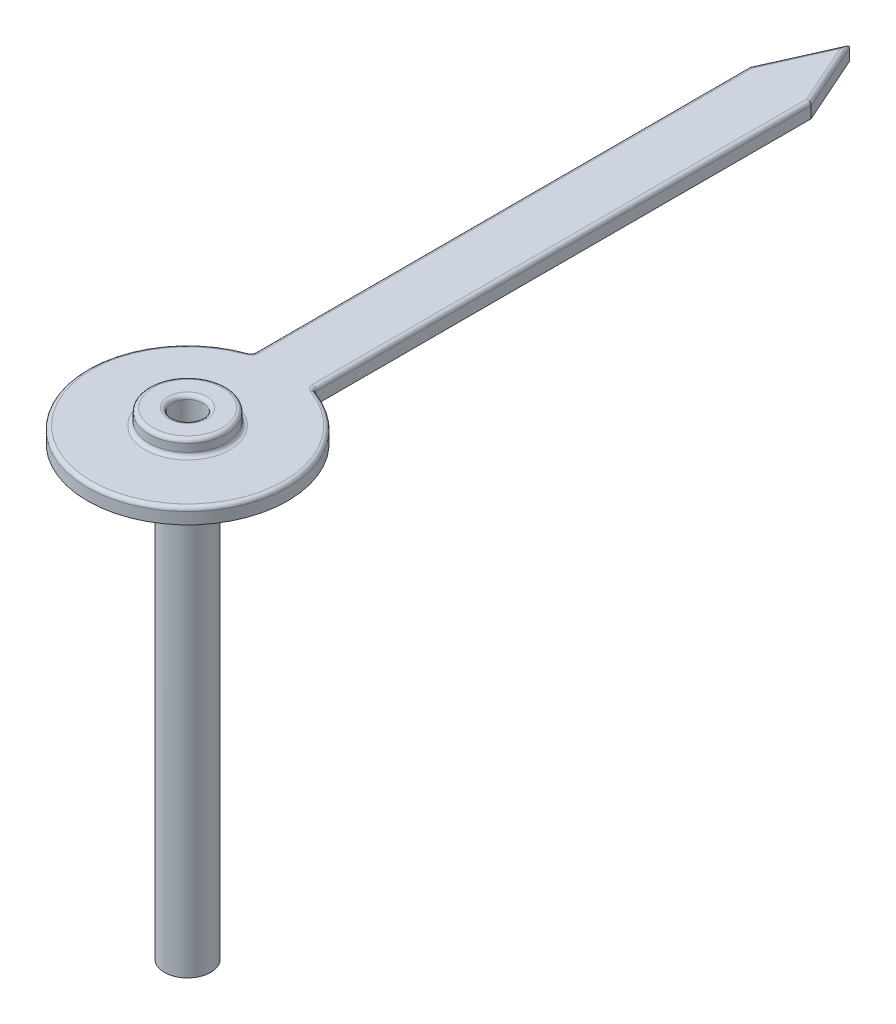
from build123d import *

# Parameters (mm, degrees)
SKETCH1_R                = 0.1
BOSS_EXTRUDE1_DEPTH      = 0.1
SKETCH2_R                = 0.25
SKETCH2_R_2              = 0.1
BOSS_EXTRUDE2_DEPTH      = 0.1
BOSS_EXTRUDE2_DEPTH_BACK = 3
FILLET1_R                = 0.025
FILLET2_R                = 0.025
SKETCH3_R                = 0.368033955
SKETCH3_R_2              = 0.15
CUT_EXTRUDE1_DEPTH       = 2.9


with BuildPart() as part:
    # Sketch1 → Boss-Extrude1 (new body)
    with BuildSketch(Plane(origin=(0, 0, 0), x_dir=(1, 0, 0), z_dir=(0, 1, 0))):
        with BuildLine():
            Line((-86.3194152, -39.054379804), (-86.3194152, -35.824941353))
            Line((-86.3194152, -35.824941353), (-86.5194152, -35.374777047))
            Line((-86.5194152, -35.374777047), (-86.7194152, -35.824941353))
            Line((-86.7194152, -35.824941353), (-86.7194152, -39.054379804))
            ThreePointArc((-86.7194152, -39.054379804), (-86.5194152, -40.322175119), (-86.3194152, -39.054379804))
        make_face()
        with Locations((-86.5194152, -39.672502044)):
            Circle(SKETCH1_R, mode=Mode.SUBTRACT)
    extrude(amount=BOSS_EXTRUDE1_DEPTH)

    # Sketch2 → Boss-Extrude2 (add, two sides)
    with BuildSketch(Plane(origin=(0, 0.1, 0), x_dir=(1, 0, 0), z_dir=(0, 1, 0))) as boss_extrude2_sk:
        with Locations((-86.5194152, -39.672502044)):
            Circle(SKETCH2_R)
        with Locations((-86.5194152, -39.672502044)):
            Circle(SKETCH2_R_2, mode=Mode.SUBTRACT)
    extrude(amount=BOSS_EXTRUDE2_DEPTH)
    extrude(boss_extrude2_sk.sketch, amount=-BOSS_EXTRUDE2_DEPTH_BACK)

    # Fillet1
    fillet1_edges = [part.edges().sort_by_distance(p)[0] for p in [
        (-86.6194152, 0.2, 39.672502044),
        (-86.7694152, 0.2, 39.672502044),
    ]]
    fillet(fillet1_edges, radius=FILLET1_R)

    # Fillet2
    fillet2_edges = [part.edges().sort_by_distance(p)[0] for p in [
        (-86.7194152, 0.1, 37.439660578),
        (-86.5194152, 0.1, 40.322175119),
        (-86.3194152, 0.1, 37.439660578),
        (-86.7694152, 0.1, 39.672502044),
        (-86.4194152, 0.1, 35.5998592),
        (-86.6194152, 0.1, 35.5998592),
        (-86.3194152, 0.05, 39.054379804),
        (-86.7194152, 0.05, 39.054379804),
    ]]
    fillet(fillet2_edges, radius=FILLET2_R)

    # Sketch3 → Cut-Extrude1 (cut)
    with BuildSketch(Plane.XZ.offset(2.9)):
        with Locations((-86.5194152, 39.672502044)):
            Circle(SKETCH3_R)
        with Locations((-86.5194152, 39.672502044)):
            Circle(SKETCH3_R_2, mode=Mode.SUBTRACT)
    extrude(amount=-CUT_EXTRUDE1_DEPTH, mode=Mode.SUBTRACT)


solid = part.part
